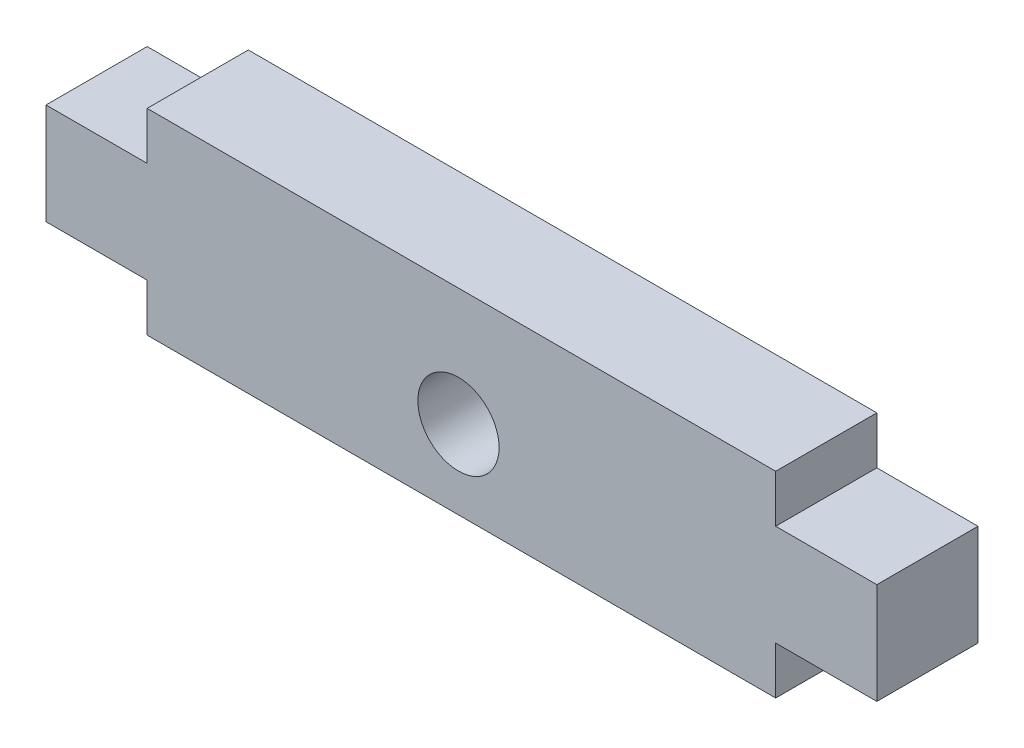
from build123d import *

# Parameters (mm, degrees)
BOSS_EXTRUDE1_DEPTH = 5.15
SKETCH2_R           = 2.0675
CUT_EXTRUDE1_DEPTH  = 6.15


with BuildPart() as part:
    # Sketch1 → Boss-Extrude1 (new body)
    with BuildSketch(Plane.XY):
        Polygon((0, 2.425), (0, 7.575), (5.15, 7.575), (5.15, 10), (37.15, 10), (37.15, 7.575), (42.3, 7.575), (42.3, 2.425), (37.15, 2.425), (37.15, 0), (5.15, 0), (5.15, 2.425), align=None)
    extrude(amount=BOSS_EXTRUDE1_DEPTH)

    # Sketch2 → Cut-Extrude1 (cut, through all)
    with BuildSketch(Plane.XY.offset(5.15)):
        with Locations((21, 4)):
            Circle(SKETCH2_R)
    extrude(amount=-CUT_EXTRUDE1_DEPTH, mode=Mode.SUBTRACT)


solid = part.part
